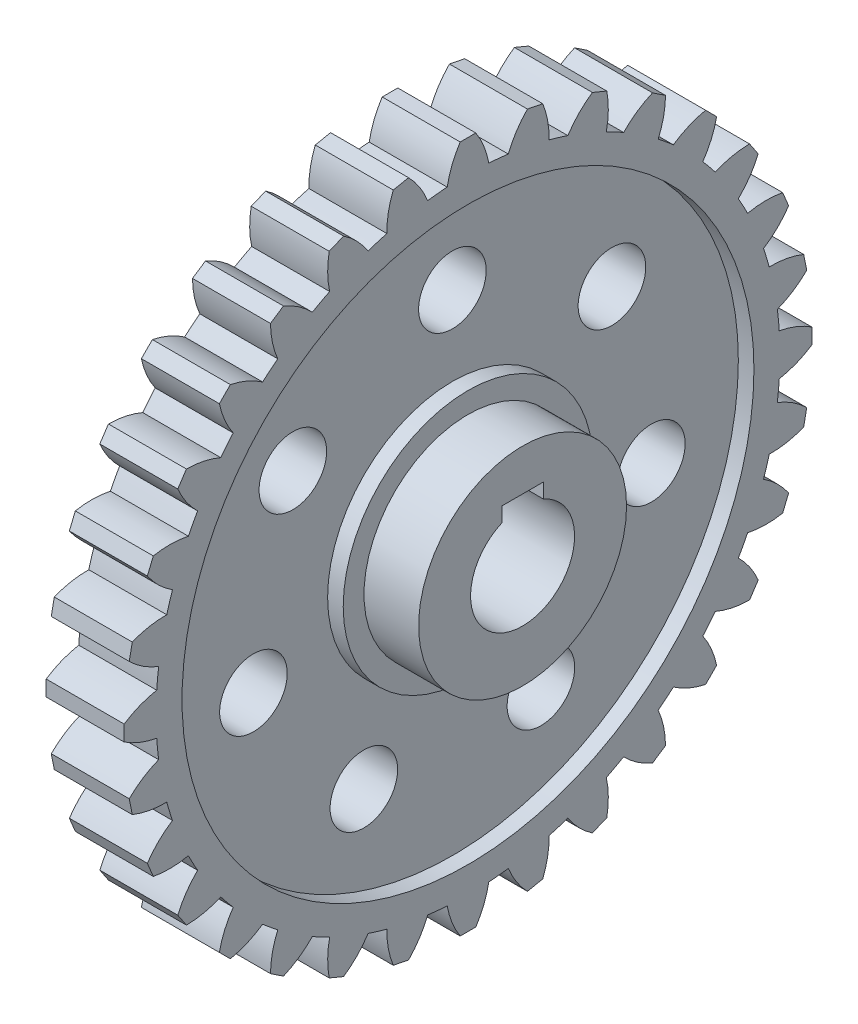
from build123d import *

# Parameters (mm, degrees)
SKETCH1_R           = 60
BOSS_EXTRUDE1_DEPTH = 7.5
BOSS_EXTRUDE2_DEPTH = 15
CIRPATTERN1_COUNT   = 32
SKETCH4_R           = 20
BOSS_EXTRUDE4_DEPTH = 18
CUT_EXTRUDE1_DEPTH  = 37
SKETCH6_R           = 55
SKETCH6_R_2         = 24
CUT_EXTRUDE2_DEPTH  = 3
SKETCH7_R           = 6.5
CUT_EXTRUDE3_DEPTH  = 23.5


with BuildPart() as part:
    # Sketch1 → Boss-Extrude1 (new body, symmetric)
    with BuildSketch(Plane(origin=(0, 0, 0), x_dir=(0, 0, -1), z_dir=(1, 0, 0))):
        Circle(SKETCH1_R)
    extrude(amount=BOSS_EXTRUDE1_DEPTH, both=True)

    # Sketch2 → Boss-Extrude2 (add)
    with BuildSketch(Plane(origin=(7.5, 0, 0), x_dir=(0, 0, -1), z_dir=(1, 0, 0))):
        with BuildLine():
            Line((-1.5, 66.133518188), (1.5, 66.133518188))
            ThreePointArc((1.5, 66.133518188), (3.064041848, 63.125294177), (4, 59.866518188))
            ThreePointArc((4, 59.866518188), (0, 60), (-4, 59.866518188))
            ThreePointArc((-4, 59.866518188), (-3.064041848, 63.125294177), (-1.5, 66.133518188))
        make_face()
    boss_extrude2 = extrude(amount=-BOSS_EXTRUDE2_DEPTH)

    # CirPattern1: Boss-Extrude2 ×32 about axis
    cirpattern1_axis = Axis((0, 0, 0), (1, 0, 0))
    for i in range(1, CIRPATTERN1_COUNT):
        add(boss_extrude2.rotate(cirpattern1_axis, i * 360 / CIRPATTERN1_COUNT))

    # Sketch4 → Boss-Extrude4 (add, symmetric)
    with BuildSketch(Plane(origin=(0, 0, 0), x_dir=(0, 0, -1), z_dir=(1, 0, 0))):
        Circle(SKETCH4_R)
    extrude(amount=BOSS_EXTRUDE4_DEPTH, both=True)

    # Sketch5 → Cut-Extrude1 (cut, through all)
    with BuildSketch(Plane(origin=(18, 0, 0), x_dir=(0, 0, -1), z_dir=(1, 0, 0))):
        with BuildLine():
            Line((-4, 12), (4, 12))
            Line((4, 12), (4, 9.16515139))
            ThreePointArc((4, 9.16515139), (0, -10), (-4, 9.16515139))
            Line((-4, 9.16515139), (-4, 12))
        make_face()
    extrude(amount=-CUT_EXTRUDE1_DEPTH, mode=Mode.SUBTRACT)

    # Sketch6 → Cut-Extrude2 (cut)
    with BuildSketch(Plane(origin=(7.5, 0, 0), x_dir=(0, 0, -1), z_dir=(1, 0, 0))):
        Circle(SKETCH6_R)
        Circle(SKETCH6_R_2, mode=Mode.SUBTRACT)
    extrude(amount=-CUT_EXTRUDE2_DEPTH, mode=Mode.SUBTRACT)

    # Sketch7 → Cut-Extrude3 (cut, through all)
    with BuildSketch(Plane(origin=(4.5, 0, 0), x_dir=(0, 0, -1), z_dir=(1, 0, 0))):
        with Locations((0, 39.25)):
            Circle(SKETCH7_R)
        with Locations((30.686885687, 24.471974723)):
            Circle(SKETCH7_R)
        with Locations((38.265920553, -8.733946658)):
            Circle(SKETCH7_R)
        with Locations((17.02993676, -35.363028065)):
            Circle(SKETCH7_R)
        with Locations((-17.02993676, -35.363028065)):
            Circle(SKETCH7_R)
        with Locations((-38.265920553, -8.733946658)):
            Circle(SKETCH7_R)
        with Locations((-30.686885687, 24.471974723)):
            Circle(SKETCH7_R)
    extrude(amount=-CUT_EXTRUDE3_DEPTH, mode=Mode.SUBTRACT)


solid = part.part
